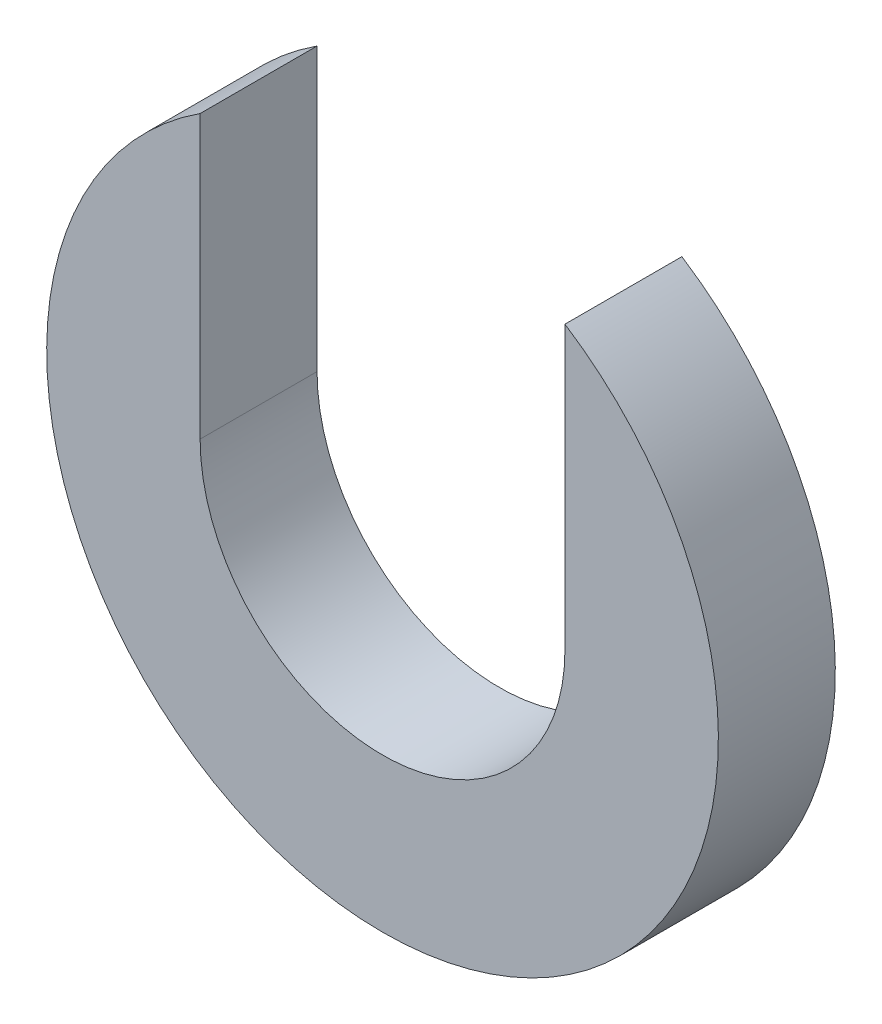
from build123d import *

# Parameters (mm, degrees)
BOSS_EXTRUDE1_DEPTH = 3.175


with BuildPart() as part:
    # Sketch1 → Boss-Extrude1 (new body)
    with BuildSketch(Plane.XY):
        with BuildLine():
            Line((-4.953, 0), (-4.953, 7.656151576))
            ThreePointArc((-4.953, 7.656151576), (0, -9.1186), (4.953, 7.656151576))
            Line((4.953, 7.656151576), (4.953, 0))
            ThreePointArc((4.953, 0), (0, -4.953), (-4.953, 0))
        make_face()
    extrude(amount=BOSS_EXTRUDE1_DEPTH)


solid = part.part
